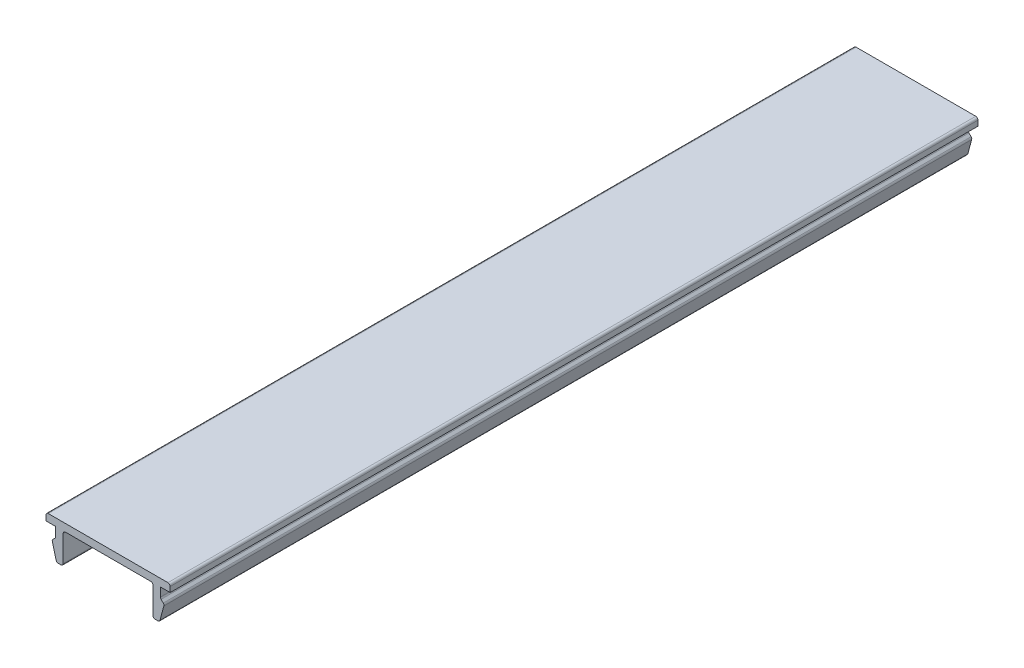
from build123d import *

# Parameters (mm, degrees)
BOSS_EXTRUDE1_DEPTH = 108
FILLET1_R           = 0.3


with BuildPart() as part:
    # Sketch1 → Boss-Extrude1 (new body)
    with BuildSketch(Plane.XY):
        Polygon((-8.3, 1), (8.3, 1), (8.3, 0), (7, 0), (7, -1.3), (7.5, -1.8), (6.883716857, -4.1), (6, -4.1), (6, 0), (-6, 0), (-6, -4.1), (-6.883716857, -4.1), (-7.5, -1.8), (-7, -1.3), (-7, 0), (-8.3, 0), align=None)
    extrude(amount=BOSS_EXTRUDE1_DEPTH)

    # Fillet1
    fillet1_edges = [part.edges().sort_by_distance(p)[0] for p in [
        (-8.3, 1, 54),
        (8.3, 1, 54),
        (7, -1.3, 54),
        (7.5, -1.8, 54),
        (6.883716857, -4.1, 54),
        (6, -4.1, 54),
        (6, 0, 54),
        (-6, 0, 54),
        (-6, -4.1, 54),
        (-6.883716857, -4.1, 54),
        (-7.5, -1.8, 54),
        (-7, -1.3, 54),
    ]]
    fillet(fillet1_edges, radius=FILLET1_R)


solid = part.part
